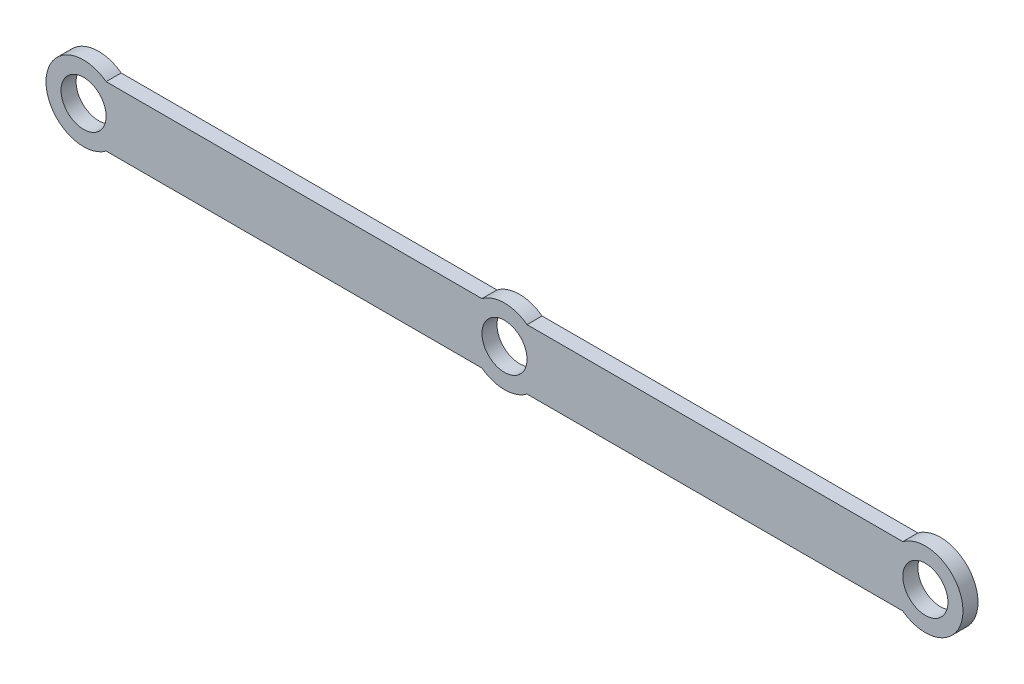
from build123d import *

# Parameters (mm, degrees)
SKETCH_1_R      = 1.5
EXTRUDE_1_DEPTH = 1


with BuildPart() as part:
    # 草图1 → 凸台-拉伸1 (new body)
    with BuildSketch(Plane.XY):
        with BuildLine():
            Line((1.5, 2), (26.5, 2))
            ThreePointArc((26.5, 2), (30.5, 0), (26.5, -2))
            Line((26.5, -2), (1.5, -2))
            ThreePointArc((1.5, -2), (0, -2.5), (-1.5, -2))
            Line((-1.5, -2), (-26.5, -2))
            ThreePointArc((-26.5, -2), (-30.5, 0), (-26.5, 2))
            Line((-26.5, 2), (-1.5, 2))
            ThreePointArc((-1.5, 2), (0, 2.5), (1.5, 2))
        make_face()
        with Locations((-28, 0)):
            Circle(SKETCH_1_R, mode=Mode.SUBTRACT)
        Circle(SKETCH_1_R, mode=Mode.SUBTRACT)
        with Locations((28, 0)):
            Circle(SKETCH_1_R, mode=Mode.SUBTRACT)
    extrude(amount=EXTRUDE_1_DEPTH)


solid = part.part
